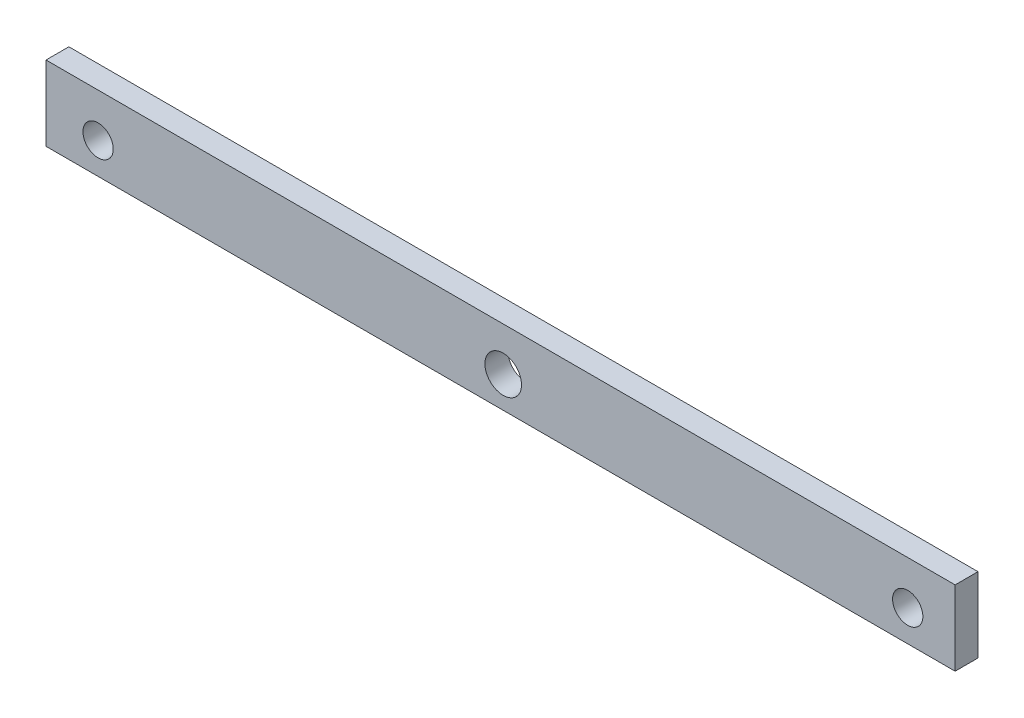
from build123d import *

# Parameters (mm, degrees)
SKETCH1_W            = 158.980651351
SKETCH1_H            = 13.078234564
BOSS_EXTRUDE1_DEPTH  = 4
M5_CLEARANCE_HOLE1_D = 5.3
M6_CLEARANCE_HOLE2_D = 6.4


with BuildPart() as part:
    # Sketch1 → Boss-Extrude1 (new body)
    with BuildSketch(Plane.XY):
        with Locations((16.171323843, -296.4446159)):
            Rectangle(SKETCH1_W, SKETCH1_H)
    extrude(amount=BOSS_EXTRUDE1_DEPTH)

    # M5 Clearance Hole1 (through all)
    with Locations(Plane.XY.offset(4)):
        with Locations((87.370998167, -297.523461342), (-54.209001833, -297.523461342)):
            Hole(M5_CLEARANCE_HOLE1_D / 2)

    # M6 Clearance Hole2 (through all)
    with Locations(Plane.XY.offset(4)):
        with Locations((16.634702444, -297.523461342)):
            Hole(M6_CLEARANCE_HOLE2_D / 2)


solid = part.part
